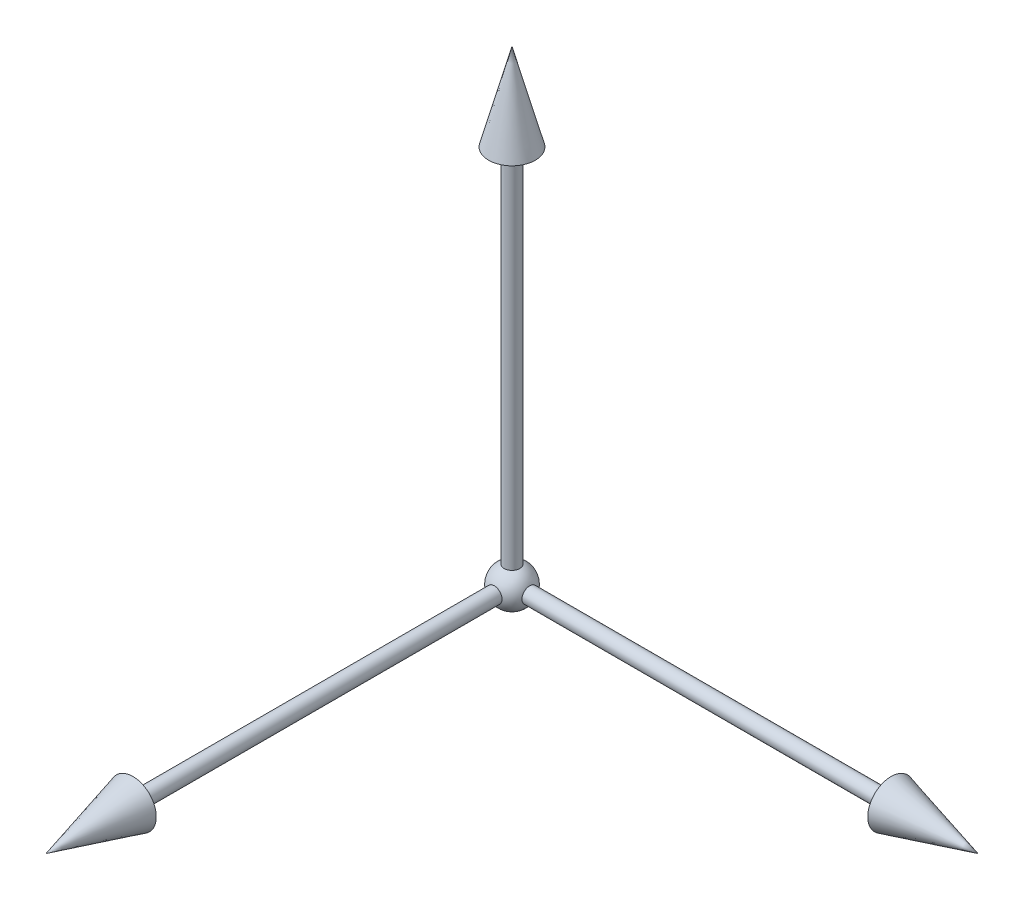
from build123d import *

# Parameters (mm, degrees)
PATTERN_CIRCULAR_1_COUNT = 2
PATTERN_CIRCULAR_1_ANGLE = 90
PATTERN_CIRCULAR_2_COUNT = 2
PATTERN_CIRCULAR_2_ANGLE = 90


with BuildPart() as part:
    # Эскиз1 → Повернуть1 (revolve)
    with BuildSketch(Plane.XY):
        Polygon((0, 30), (0, 0), (0.5, 0), (0.5, 24.401923789), (1.5, 24.401923789), align=None)
    revolve(axis=Axis((0, 0, 0), (0, 1, 0)))


with BuildPart() as pattern_circular_1_1:
    # Круговой массив1: pattern copy
    add(part.part.rotate(Axis((-80.9, 0, 0), (1, 0, 0)), 1 * PATTERN_CIRCULAR_1_ANGLE / (PATTERN_CIRCULAR_1_COUNT - 1)))


with BuildPart() as pattern_circular_2_1:
    # Круговой массив2: pattern copy
    add(part.part.rotate(Axis((0, 0, -80.9), (0, 0, -1)), 1 * PATTERN_CIRCULAR_2_ANGLE / (PATTERN_CIRCULAR_2_COUNT - 1)))


with BuildPart() as body_4:
    # Эскиз2 → Повернуть2 (revolve)
    with BuildSketch(Plane.XY):
        with BuildLine():
            Line((0, 1.25), (0, -1.25))
            ThreePointArc((0, -1.25), (1.25, 0), (0, 1.25))
        make_face()
    revolve(axis=Axis((0, 1.25, 0), (0, -1, 0)))


solid = Compound([part.part, pattern_circular_1_1.part, pattern_circular_2_1.part, body_4.part])
